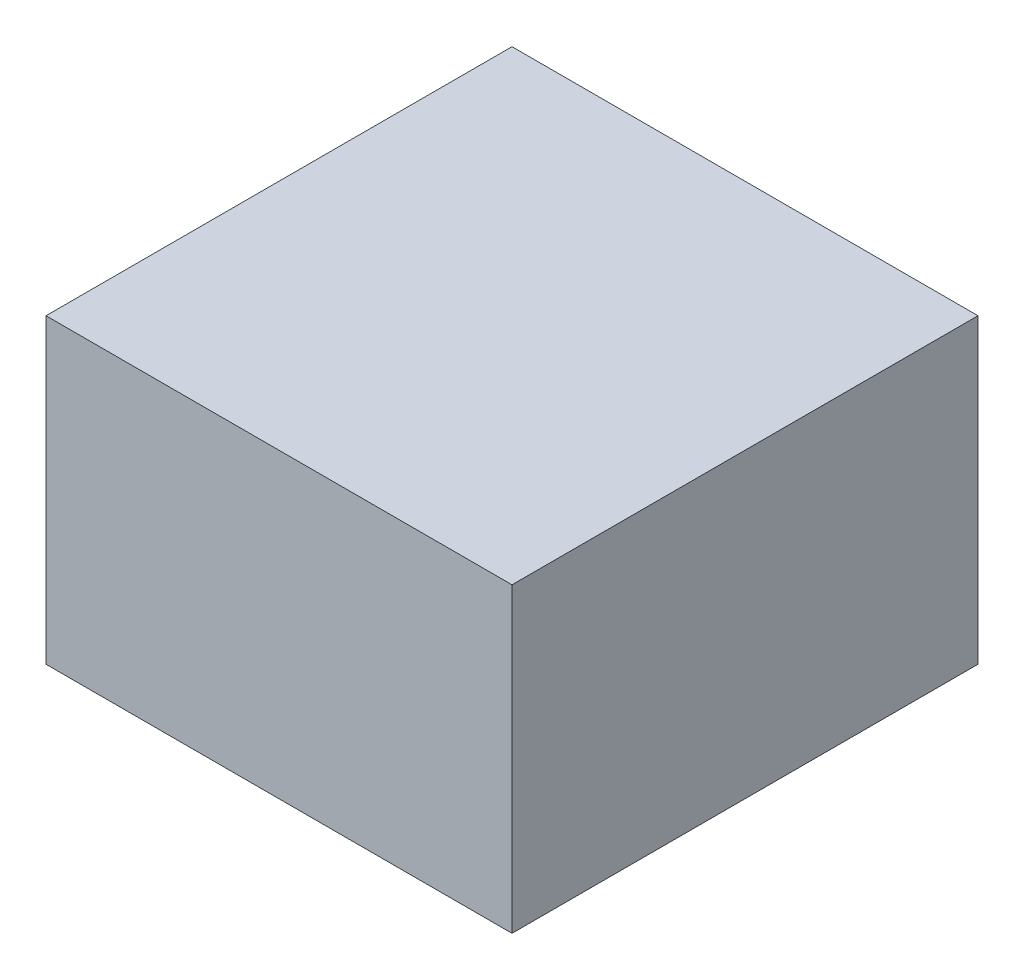
from build123d import *

# Parameters (mm, degrees)
SKETCH1_W           = 1.76
SKETCH1_H           = 1.76
BOSS_EXTRUDE1_DEPTH = 1.14


with BuildPart() as part:
    # Sketch1 → Boss-Extrude1 (new body)
    with BuildSketch(Plane(origin=(0, 0, 0), x_dir=(1, 0, 0), z_dir=(0, 1, 0))):
        Rectangle(SKETCH1_W, SKETCH1_H)
    extrude(amount=BOSS_EXTRUDE1_DEPTH)


solid = part.part
